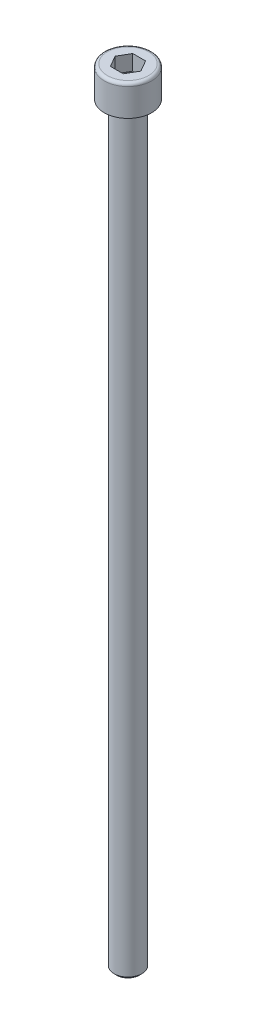
from build123d import *

# Parameters (mm, degrees)
ESQUISSE2_R             = 2.5
BASE_EXTRUSION_DEPTH    = 135
CHANFREIN1_SIZE         = 0.5
ENL_V_MAT_EXTRU_1_DEPTH = 2.75


with BuildPart() as part:
    # Esquisse2 → Base-Extrusion (new body)
    with BuildSketch(Plane(origin=(0, 0, 0), x_dir=(1, 0, 0), z_dir=(0, 1, 0))):
        with Locations(Location((0, 0, 0), (0, 0, 270))):  # turned: the seam where the file's is
            Circle(ESQUISSE2_R)
    extrude(amount=-BASE_EXTRUSION_DEPTH)

    # Chanfrein1
    chanfrein1_edges = [part.edges().sort_by_distance(p)[0] for p in [
        (0, -135, -2.5),
    ]]
    chamfer(chanfrein1_edges, length=CHANFREIN1_SIZE)

    # Esquisse5 → Boss.-Révol.1 (revolve)
    with BuildSketch(Plane.XY, mode=Mode.PRIVATE) as boss_r_vol_1_sk:
        with BuildLine():
            Line((2, 5.5), (2, 2.75))
            Line((2, 2.75), (0, 1.595299462))
            Line((0, 1.595299462), (0, 0))
            Line((0, 0), (4.25, 0))
            Line((4.25, 0), (4.25, 4.95))
            ThreePointArc((4.25, 4.95), (4.08890873, 5.33890873), (3.7, 5.5))
            Line((3.7, 5.5), (2, 5.5))
        make_face()
    revolve(boss_r_vol_1_sk.sketch.rotate(Axis((0, 5.5, 0), (0, -1, 0)), 90), axis=Axis((0, 5.5, 0), (0, -1, 0)))  # turned: the seam where the file's is

    # Esquisse7 → Enlèv. mat.-Extru.1 (cut)
    with BuildSketch(Plane(origin=(0, 5.5, 0), x_dir=(-1, 0, 0), z_dir=(0, 1, 0))):
        Polygon((1.154700538, 2), (-1.154700538, 2), (-2.309401077, 0), (-1.154700538, -2), (1.154700538, -2), (2.309401077, 0), align=None)
    extrude(amount=-ENL_V_MAT_EXTRU_1_DEPTH, mode=Mode.SUBTRACT)


solid = part.part
